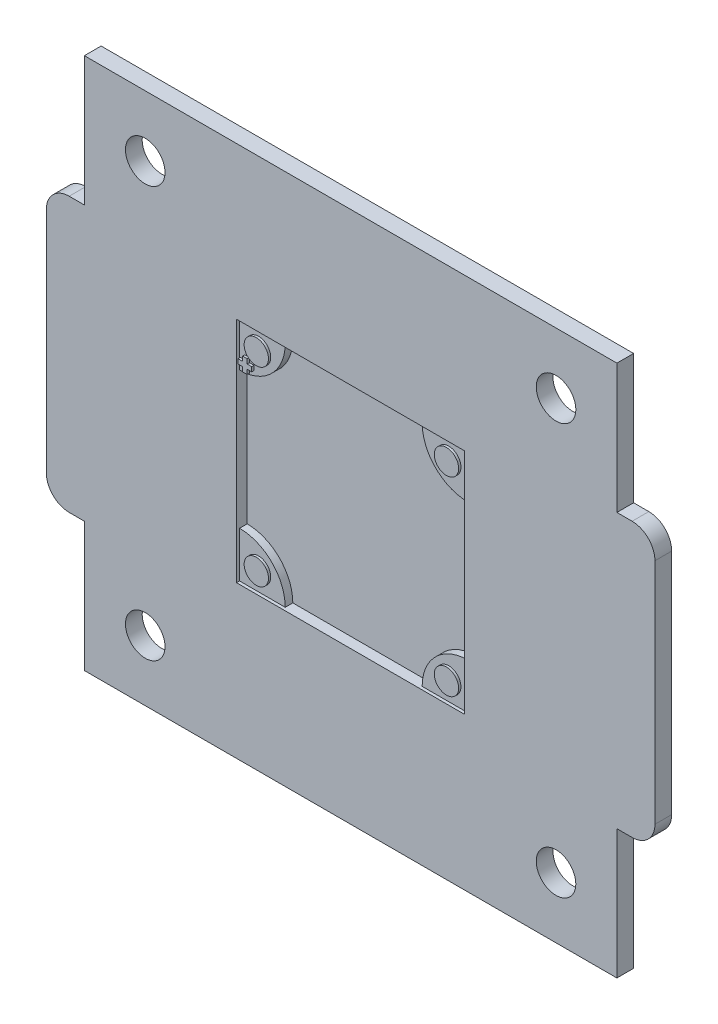
from build123d import *

# Parameters (mm, degrees)
SKETCH_1_W          = 70
SKETCH_1_H          = 70
EXTRUDE_1_DEPTH     = 2.2
SKETCH_2_W          = 30
SKETCH_2_H          = 30
CUT_EXTRUDE_1_DEPTH = 1.4
SKETCH_3_R          = 2.6
CUT_EXTRUDE_2_DEPTH = 3.2
EXTRUDE_2_DEPTH     = 1.8
SKETCH_6_R          = 1.6
EXTRUDE_3_DEPTH     = 0.3


with BuildPart() as part:
    # 草图1 → 凸台-拉伸1 (new body)
    with BuildSketch(Plane.XY):
        with BuildLine():
            Line((-2, 17), (0, 17))
            Line((0, 17), (0, 53))
            Line((0, 53), (-2, 53))
            ThreePointArc((-2, 53), (-4.121320344, 52.121320344), (-5, 50))
            Line((-5, 50), (-5, 20))
            ThreePointArc((-5, 20), (-4.121320344, 17.878679656), (-2, 17))
        make_face()
        with Locations((35, 35)):
            Rectangle(SKETCH_1_W, SKETCH_1_H)
        with BuildLine():
            Line((70, 53), (70, 17))
            Line((70, 17), (72, 17))
            ThreePointArc((72, 17), (74.121320344, 17.878679656), (75, 20))
            Line((75, 20), (75, 50))
            ThreePointArc((75, 50), (74.121320344, 52.121320344), (72, 53))
            Line((72, 53), (70, 53))
        make_face()
    extrude(amount=EXTRUDE_1_DEPTH)

    # 草图2 → 切除-拉伸1 (cut)
    with BuildSketch(Plane.XY.offset(2.2)):
        with Locations((35, 35)):
            Rectangle(SKETCH_2_W, SKETCH_2_H)
    extrude(amount=-CUT_EXTRUDE_1_DEPTH, mode=Mode.SUBTRACT)

    # 草图3 → 切除-拉伸2 (cut, through all)
    with BuildSketch(Plane.XY.offset(2.2)):
        with Locations((8, 62)):
            Circle(SKETCH_3_R)
        with Locations((62, 62)):
            Circle(SKETCH_3_R)
        with Locations((8, 8)):
            Circle(SKETCH_3_R)
        with Locations((62, 8)):
            Circle(SKETCH_3_R)
    extrude(amount=-CUT_EXTRUDE_2_DEPTH, mode=Mode.SUBTRACT)

    # 草图4 → 凸台-拉伸2 (add)
    with BuildSketch(Plane.XY):
        with BuildLine():
            Line((20, 44), (20, 50))
            Line((20, 50), (26, 50))
            ThreePointArc((26, 50), (24.242640687, 45.757359313), (20, 44))
        make_face()
        with BuildLine():
            Line((50, 44), (50, 50))
            Line((50, 50), (44, 50))
            ThreePointArc((44, 50), (45.757359313, 45.757359313), (50, 44))
        make_face()
        with BuildLine():
            Line((50, 20), (44, 20))
            ThreePointArc((44, 20), (45.757359313, 24.242640687), (50, 26))
            Line((50, 26), (50, 20))
        make_face()
        with BuildLine():
            Line((20, 26), (20, 20))
            Line((20, 20), (26, 20))
            ThreePointArc((26, 20), (24.242640687, 24.242640687), (20, 26))
        make_face()
    extrude(amount=EXTRUDE_2_DEPTH)

    # 草图6 → 凸台-拉伸3 (add)
    with BuildSketch(Plane.XY.offset(1.8)):
        with Locations((22.5, 47.5)):
            Circle(SKETCH_6_R)
        with Locations((47.5, 47.5)):
            Circle(SKETCH_6_R)
        with Locations((47.5, 22.5)):
            Circle(SKETCH_6_R)
        with Locations((22.5, 22.5)):
            Circle(SKETCH_6_R)
        Polygon((20.1, 45.5), (20.7, 45.5), (20.7, 46.1), (21.3, 46.1), (21.3, 45.5), (21.9, 45.5), (21.9, 44.9), (21.3, 44.9), (21.3, 44.3), (20.7, 44.3), (20.7, 44.9), (20.1, 44.9), align=None)
    extrude(amount=EXTRUDE_3_DEPTH)


solid = part.part
